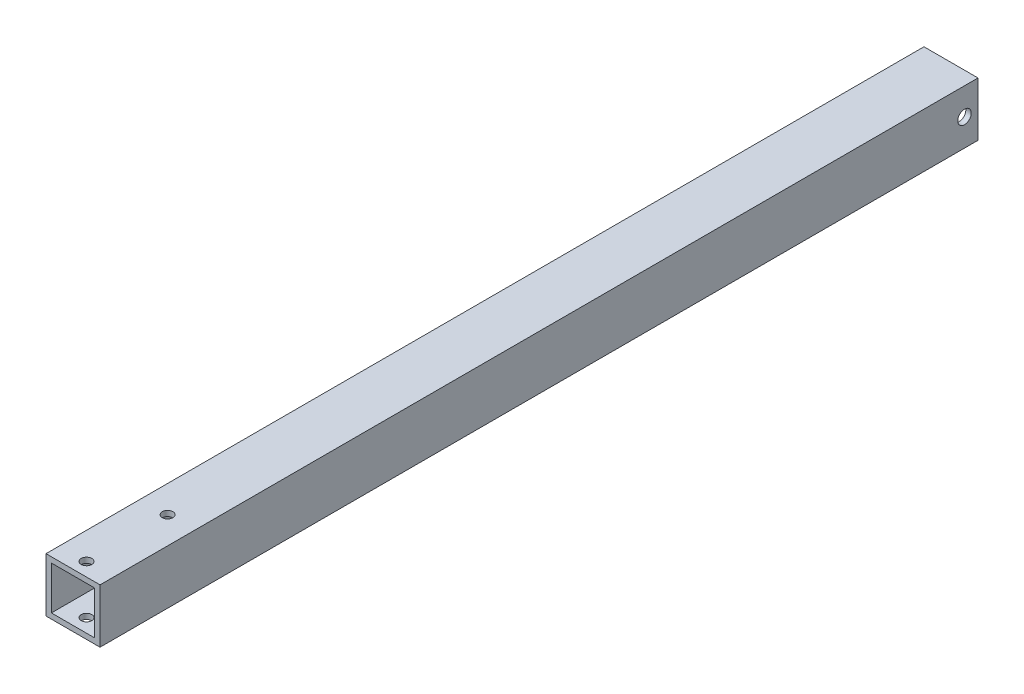
from build123d import *

# Parameters (mm, degrees)
SKETCH1_W           = 25.4
SKETCH1_H           = 25.4
SKETCH1_W_2         = 20.32
SKETCH1_H_2         = 20.32
EXTRUDE_THIN1_DEPTH = 412.75
SKETCH2_R           = 2.4892
CUT_EXTRUDE1_DEPTH  = 26.4
SKETCH3_R           = 3.175
CUT_EXTRUDE2_DEPTH  = 26.4


with BuildPart() as part:
    # Sketch1 → Extrude-Thin1 (new body)
    with BuildSketch(Plane.XY):
        Rectangle(SKETCH1_W, SKETCH1_H)
        Rectangle(SKETCH1_W_2, SKETCH1_H_2, mode=Mode.SUBTRACT)
    extrude(amount=EXTRUDE_THIN1_DEPTH)

    # Sketch2 → Cut-Extrude1 (cut, through all)
    with BuildSketch(Plane(origin=(0, 12.7, 0), x_dir=(1, 0, 0), z_dir=(0, 1, 0))):
        with Locations((0, -406.4)):
            Circle(SKETCH2_R)
        with Locations((0, -368.3)):
            Circle(SKETCH2_R)
    extrude(amount=-CUT_EXTRUDE1_DEPTH, mode=Mode.SUBTRACT)

    # Sketch3 → Cut-Extrude2 (cut, through all)
    with BuildSketch(Plane(origin=(12.7, 0, 0), x_dir=(0, 0, -1), z_dir=(1, 0, 0))):
        with Locations((-6.35, 0)):
            Circle(SKETCH3_R)
    extrude(amount=-CUT_EXTRUDE2_DEPTH, mode=Mode.SUBTRACT)


solid = part.part
